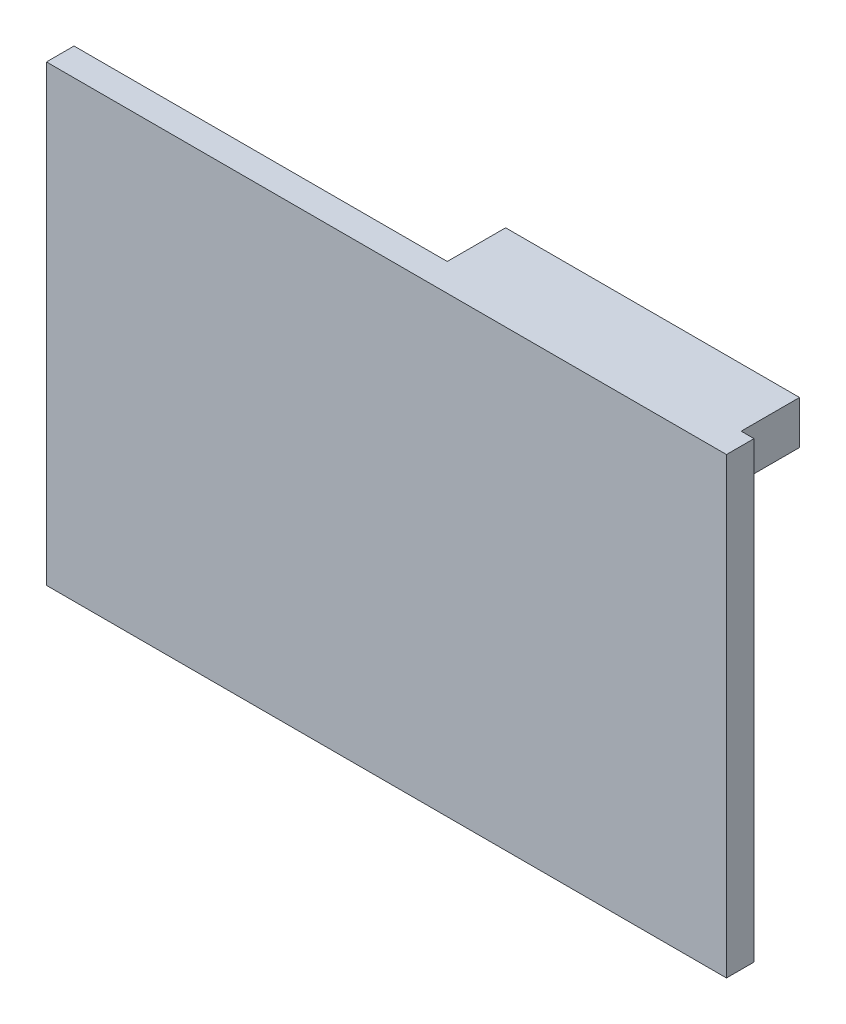
from build123d import *

# Parameters (mm, degrees)
SKETCH1_W           = 73.969271166
SKETCH1_H           = 49.312847444
BOSS_EXTRUDE1_DEPTH = 3.000000096
SKETCH2_W           = 31.971798189
SKETCH2_H           = 4.7152652
BOSS_EXTRUDE2_DEPTH = 6.35


with BuildPart() as part:
    # Sketch1 → Boss-Extrude1 (new body)
    with BuildSketch(Plane.XY):
        Rectangle(SKETCH1_W, SKETCH1_H)
    extrude(amount=BOSS_EXTRUDE1_DEPTH)

    # Sketch2 → Boss-Extrude2 (add)
    with BuildSketch(Plane.XY):
        with Locations((19.598546823, 22.298791122)):
            Rectangle(SKETCH2_W, SKETCH2_H)
    extrude(amount=-BOSS_EXTRUDE2_DEPTH)


solid = part.part
